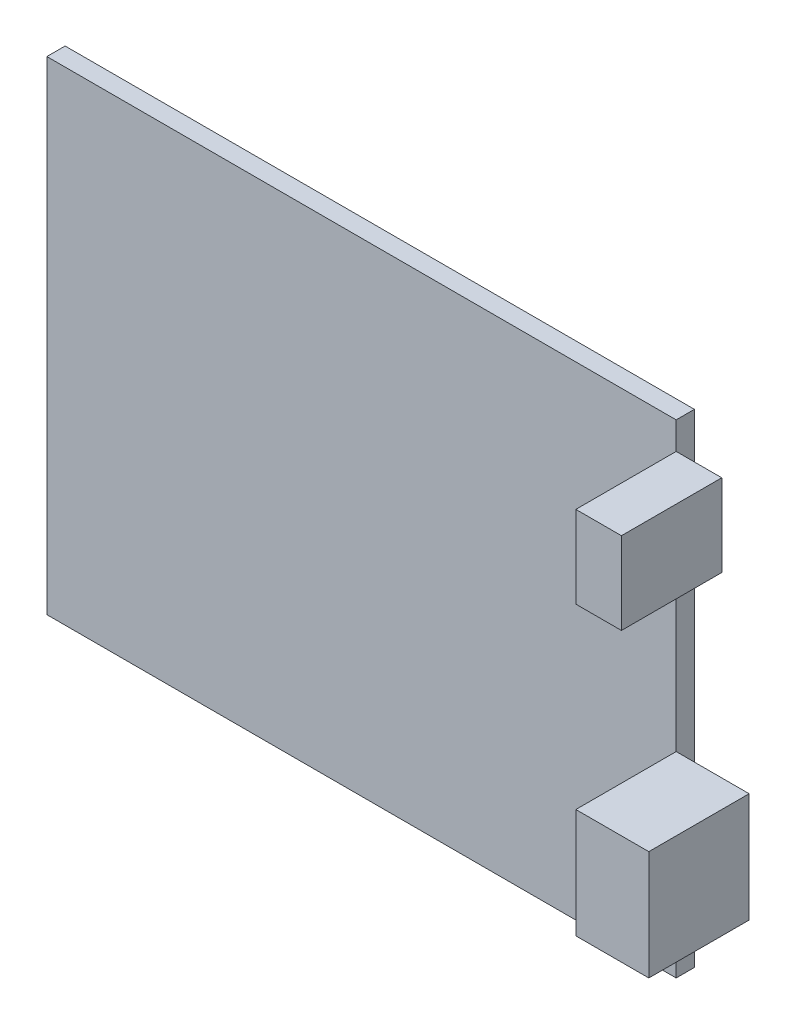
from build123d import *

# Parameters (mm, degrees)
ESBO_O1_W                  = 69
ESBO_O1_H                  = 53
RESSALTO_EXTRUS_O1_DEPTH   = 2
ESBO_O2_W                  = 11
ESBO_O2_H                  = 9
RESSALTO_EXTRUS_O2_DEPTH   = 5
ESBO_O2_H_2                = 12
RESSALTO_EXTRUS_O2_2_DEPTH = 5
ESBO_O3_W                  = 11
ESBO_O3_H                  = 12
RESSALTO_EXTRUS_O3_DEPTH   = 3


with BuildPart() as part:
    # Esboço1 → Ressalto-extrusão1 (new body)
    with BuildSketch(Plane.XY):
        with Locations((34.5, 26.5)):
            Rectangle(ESBO_O1_W, ESBO_O1_H)
    extrude(amount=RESSALTO_EXTRUS_O1_DEPTH)


with BuildPart() as body_2:
    # Esboço2 → Ressalto-extrusão2 (new body)
    with BuildSketch(Plane(origin=(69, 0, 0), x_dir=(0, 0, -1), z_dir=(1, 0, 0))):
        with Locations((-7.5, 45.5)):
            Rectangle(ESBO_O2_W, ESBO_O2_H)
    extrude(amount=RESSALTO_EXTRUS_O2_DEPTH)


with BuildPart() as body_3:
    # Esboço2 → Ressalto-extrus_o2 2 (new body)
    with BuildSketch(Plane(origin=(69, 0, 0), x_dir=(0, 0, -1), z_dir=(1, 0, 0))):
        with Locations((-7.5, 15.5)):
            Rectangle(ESBO_O2_W, ESBO_O2_H_2)
    extrude(amount=RESSALTO_EXTRUS_O2_2_DEPTH)

    # Esboço3 → Ressalto-extrusão3 (add)
    with BuildSketch(Plane(origin=(74, 0, 0), x_dir=(0, 0, -1), z_dir=(1, 0, 0))):
        with Locations((-7.5, 15.5)):
            Rectangle(ESBO_O3_W, ESBO_O3_H)
    extrude(amount=RESSALTO_EXTRUS_O3_DEPTH)


solid = Compound([part.part, body_2.part, body_3.part])
